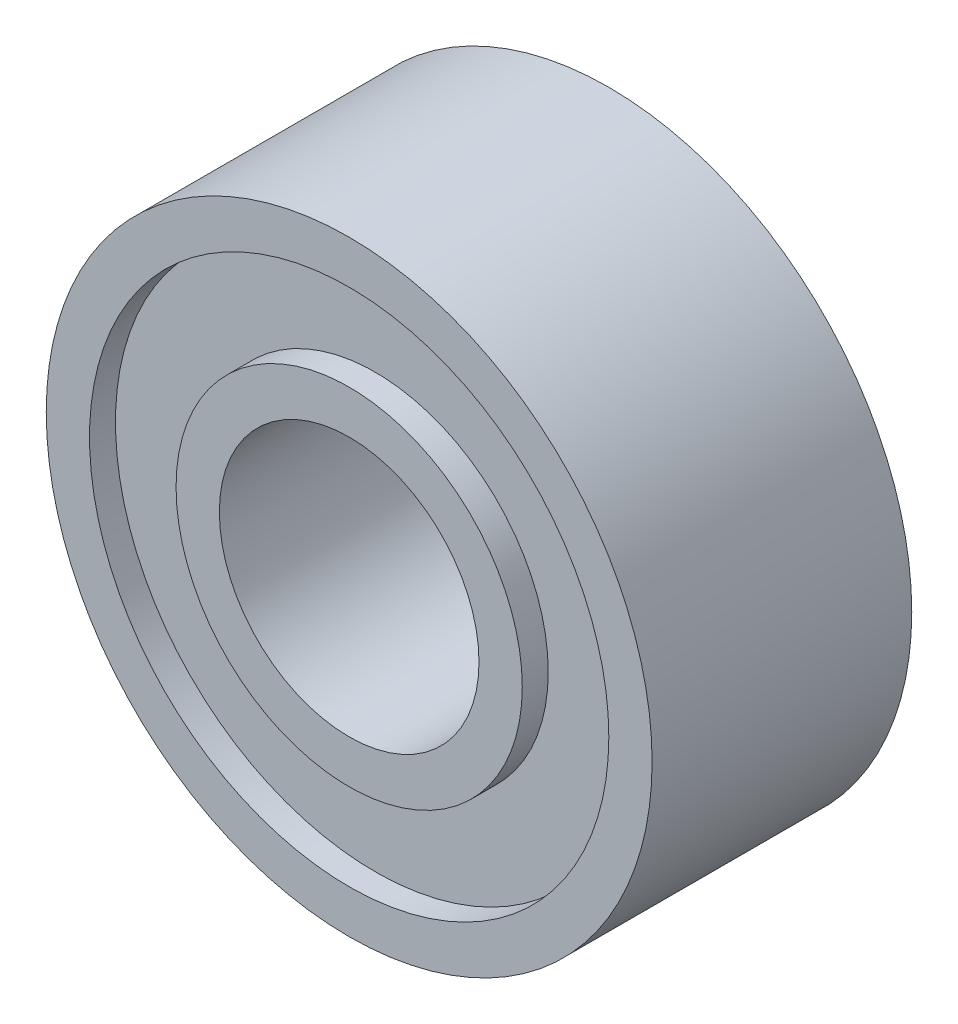
from build123d import *

# Parameters (mm, degrees)
SKETCH1_R           = 3.5
SKETCH1_R_2         = 1.5
BOSS_EXTRUDE1_DEPTH = 3
SKETCH2_R           = 3
SKETCH2_R_2         = 2
CUT_EXTRUDE1_DEPTH  = 0.3
CUT_EXTRUDE2_START  = -3
SKETCH2_2_R         = 3
SKETCH2_2_R_2       = 2
CUT_EXTRUDE2_DEPTH  = 0.3


with BuildPart() as part:
    # Sketch1 → Boss-Extrude1 (new body)
    with BuildSketch(Plane.XY):
        Circle(SKETCH1_R)
        Circle(SKETCH1_R_2, mode=Mode.SUBTRACT)
    extrude(amount=BOSS_EXTRUDE1_DEPTH)

    # Sketch2 → Cut-Extrude1 (cut)
    with BuildSketch(Plane.XY.offset(3)):
        Circle(SKETCH2_R)
        Circle(SKETCH2_R_2, mode=Mode.SUBTRACT)
    extrude(amount=-CUT_EXTRUDE1_DEPTH, mode=Mode.SUBTRACT)

    # Sketch2_2 → Cut-Extrude2 (cut)
    with BuildSketch(Plane.XY.offset(3).offset(CUT_EXTRUDE2_START)):
        Circle(SKETCH2_2_R)
        Circle(SKETCH2_2_R_2, mode=Mode.SUBTRACT)
    extrude(amount=CUT_EXTRUDE2_DEPTH, mode=Mode.SUBTRACT)


solid = part.part
